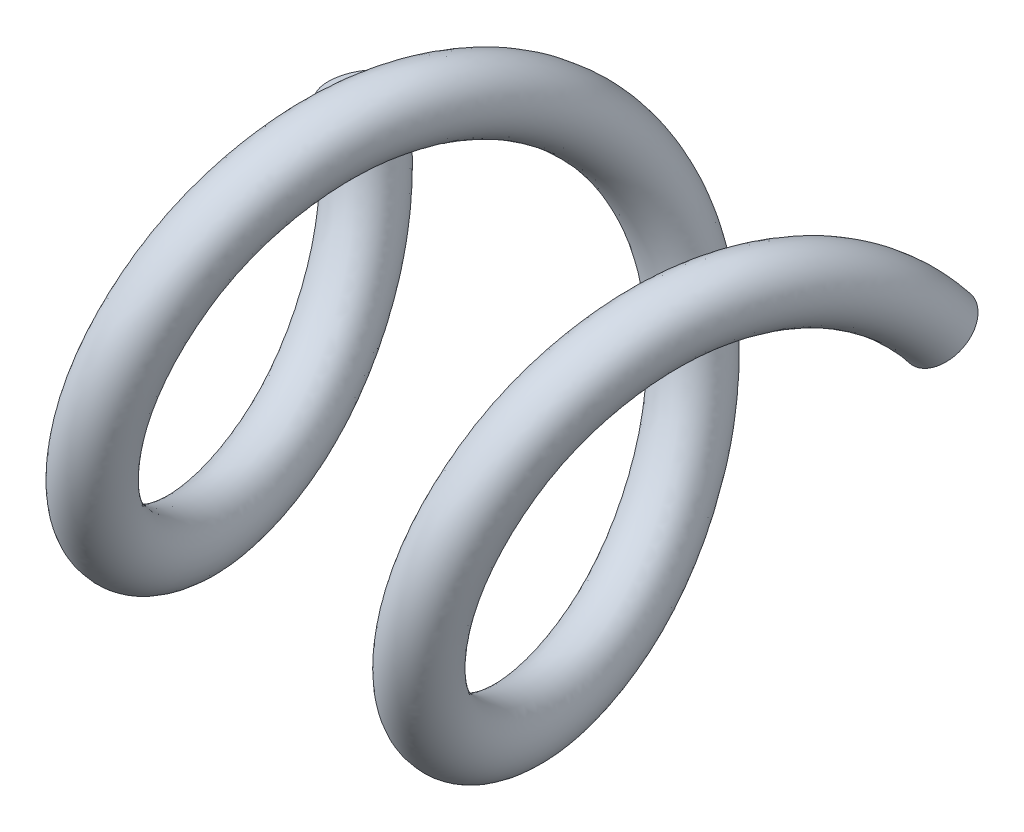
from build123d import *

# Parameters (mm, degrees)
SWEEP1_PITCH       = 2
SWEEP1_HEIGHT      = 3.8
SWEEP1_RADIUS      = 1.3
SWEEP1_START_ANGLE = 180
SKETCH2_R          = 0.2


with BuildPart() as part:
    # Sweep1: sweep along a helix
    with BuildLine() as sweep1_path:
        add(Helix(SWEEP1_PITCH, SWEEP1_HEIGHT, SWEEP1_RADIUS, center=(0, 0, 0), direction=(1, 0, 0), lefthand=True, mode=Mode.PRIVATE).rotate(Axis((0, 0, 0), (1, 0, 0)), SWEEP1_START_ANGLE))
    # Sketch2 → Sweep1 (sweep)
    with BuildSketch(Plane(origin=(3.8, 0.764120828, -1.051722093), x_dir=(-0.957918413, -0.287012728, -0.004001034), z_dir=(0.237828226, -0.785804056, -0.570920065))):
        Circle(SKETCH2_R)
    sweep(path=sweep1_path.line, is_frenet=True)


solid = part.part
